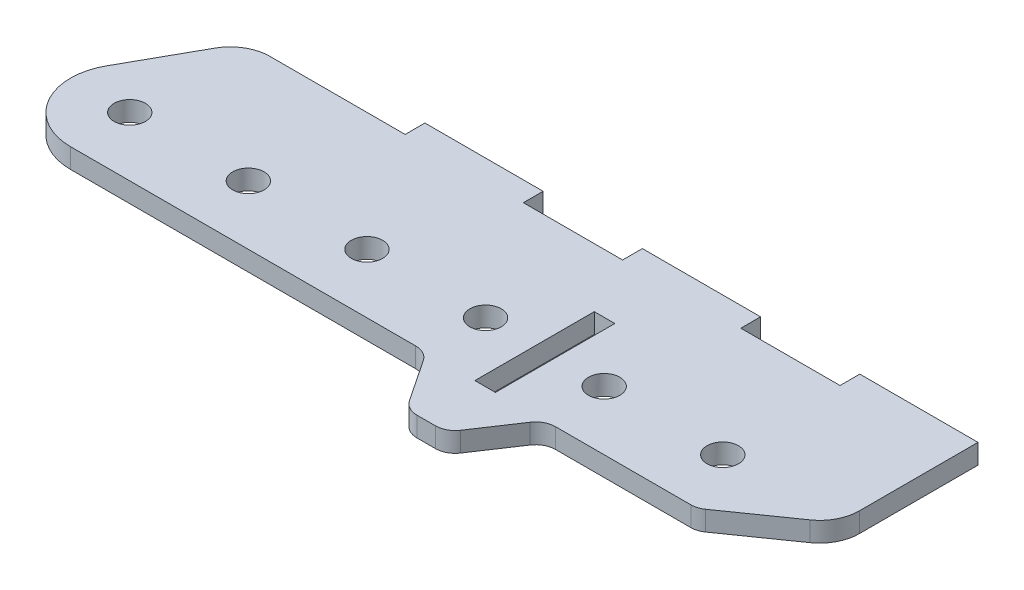
from build123d import *

# Parameters (mm, degrees)
SKETCH1_W               = 304.8
SKETCH1_H               = 76.2
BOSS_EXTRUDE1_DEPTH     = 6.35
CHAMFER1_SIZE           = 53.975
CHAMFER1_SIZE2          = 37.793701875
SKETCH2_W               = 37.973
SKETCH2_H               = 6.35
BOSS_EXTRUDE2_DEPTH     = 6.35
LPATTERN1_COUNT         = 3
LPATTERN1_PITCH         = 69.85
F_3_8_CLEARANCE_HOLE1_D = 10.0838
CUT_EXTRUDE1_DEPTH      = 7.35
FILLET1_R               = 12.7
SKETCH7_W               = 6.604
SKETCH7_H               = 38.354
CUT_EXTRUDE2_DEPTH      = 7.35
CUT_EXTRUDE3_DEPTH      = 7.35
FILLET2_R               = 6.35


with BuildPart() as part:
    # Sketch1 → Boss-Extrude1 (new body)
    with BuildSketch(Plane(origin=(0, 0, 0), x_dir=(1, 0, 0), z_dir=(0, 1, 0))):
        with Locations((-152.4, -38.1)):
            Rectangle(SKETCH1_W, SKETCH1_H)
    extrude(amount=BOSS_EXTRUDE1_DEPTH)

    # Chamfer1
    chamfer1_edges = [part.edges().sort_by_distance(p)[0] for p in [
        (0, 3.175, 76.2),
    ]]
    chamfer1_side = [part.faces().sort_by_distance(p)[0] for p in [
        (-152.4, 3.175, 76.2),
    ]]
    chamfer(chamfer1_edges, length=CHAMFER1_SIZE, length2=CHAMFER1_SIZE2, reference=chamfer1_side[0])

    # Sketch2 → Boss-Extrude2 (add)
    with BuildSketch(Plane(origin=(0, 6.35, 0), x_dir=(1, 0, 0), z_dir=(0, 1, 0))):
        with Locations((-18.9865, 3.175)):
            Rectangle(SKETCH2_W, SKETCH2_H)
    boss_extrude2 = extrude(amount=-BOSS_EXTRUDE2_DEPTH)

    # LPattern1: Boss-Extrude2 ×3
    with Locations(*[(-i * LPATTERN1_PITCH, 0, 0) for i in range(1, LPATTERN1_COUNT)]):
        add(boss_extrude2)

    # 3/8 Clearance Hole1 (through all)
    with Locations(Plane(origin=(0, 6.35, 0), x_dir=(1, 0, 0), z_dir=(0, 1, 0))):
        with Locations((-37.5406093, -38.1), (-75.6406093, -38.1), (-113.7406093, -38.1), (-151.8406093, -38.1), (-189.9406093, -38.1), (-228.0406093, -38.1)):
            Hole(F_3_8_CLEARANCE_HOLE1_D / 2)

    # Sketch6 → Cut-Extrude1 (cut, through all)
    with BuildSketch(Plane(origin=(0, 6.35, 0), x_dir=(1, 0, 0), z_dir=(0, 1, 0))):
        with BuildLine():
            Line((-244.677025408, -28.8192587), (-228.6, 0))
            Line((-228.6, 0), (-304.8, 0))
            Line((-304.8, 0), (-304.8, -76.2))
            Line((-304.8, -76.2), (-228.6, -76.2))
            Line((-228.6, -76.2), (-244.677025408, -47.3807413))
            ThreePointArc((-244.677025408, -47.3807413), (-247.0906093, -38.1), (-244.677025408, -28.8192587))
        make_face()
    extrude(amount=-CUT_EXTRUDE1_DEPTH, mode=Mode.SUBTRACT)

    # Fillet1
    fillet1_edges = [part.edges().sort_by_distance(p)[0] for p in [
        (-228.6, 3.175, 76.2),
        (-228.6, 3.175, 0),
        (0, 3.175, 38.406298125),
        (-53.975, 3.175, 76.2),
    ]]
    fillet(fillet1_edges, radius=FILLET1_R)

    # Sketch7 → Cut-Extrude2 (cut, through all)
    with BuildSketch(Plane(origin=(0, 6.35, 0), x_dir=(1, 0, 0), z_dir=(0, 1, 0))):
        with Locations((-94.6906093, -38.1)):
            Rectangle(SKETCH7_W, SKETCH7_H)
    extrude(amount=-CUT_EXTRUDE2_DEPTH, mode=Mode.SUBTRACT)

    # Sketch8 → Cut-Extrude3 (cut, through all)
    with BuildSketch(Plane(origin=(0, 6.35, 0), x_dir=(1, 0, 0), z_dir=(0, 1, 0))):
        with BuildLine():
            Line((-113.7406093, -57.15), (-228.0406093, -57.15))
            ThreePointArc((-228.0406093, -57.15), (-237.686965561, -54.527121199), (-244.677025408, -47.3807413))
            Line((-244.677025408, -47.3807413), (-232.233232947, -69.687160867))
            ThreePointArc((-232.233232947, -69.687160867), (-227.573193049, -74.451414133), (-221.142288875, -76.2))
            Line((-221.142288875, -76.2), (-101.0406093, -76.2))
            Line((-101.0406093, -76.2), (-113.7406093, -57.15))
        make_face()
        with BuildLine():
            Line((-75.6406093, -57.15), (-88.3406093, -76.2))
            Line((-88.3406093, -76.2), (-57.979294619, -76.2))
            ThreePointArc((-57.979294619, -76.2), (-54.160330965, -75.612205275), (-50.694873877, -73.903230962))
            Line((-50.694873877, -73.903230962), (-26.768780472, -57.15))
            Line((-26.768780472, -57.15), (-75.6406093, -57.15))
        make_face()
    extrude(amount=-CUT_EXTRUDE3_DEPTH, mode=Mode.SUBTRACT)

    # Fillet2
    fillet2_edges = [part.edges().sort_by_distance(p)[0] for p in [
        (-113.7406093, 3.175, 57.15),
        (-101.0406093, 3.175, 76.2),
        (-75.6406093, 3.175, 57.15),
        (-26.768780472, 3.175, 57.15),
        (-88.3406093, 3.175, 76.2),
    ]]
    fillet(fillet2_edges, radius=FILLET2_R)


solid = part.part
